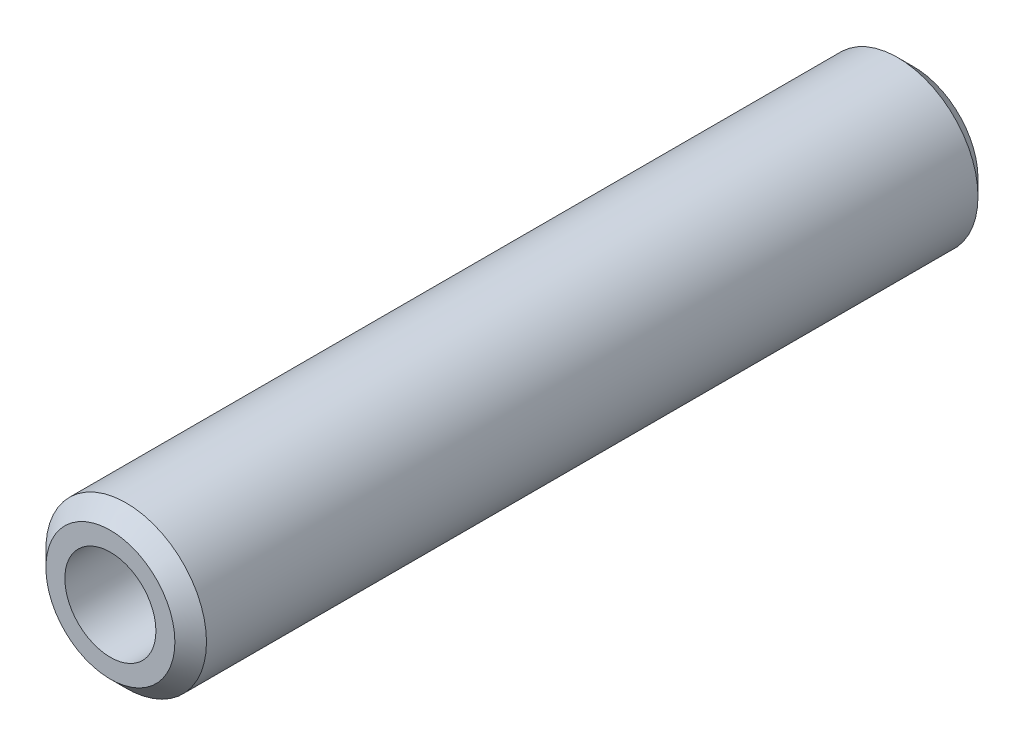
from build123d import *

# Parameters (mm, degrees)
SKETCH1_R           = 12.7
SKETCH1_R_2         = 7.2
BOSS_EXTRUDE1_DEPTH = 63.5
CHAMFER1_SIZE       = 2.5


with BuildPart() as part:
    # Sketch1 → Boss-Extrude1 (new body, symmetric)
    with BuildSketch(Plane.XY):
        Circle(SKETCH1_R)
        Circle(SKETCH1_R_2, mode=Mode.SUBTRACT)
    extrude(amount=BOSS_EXTRUDE1_DEPTH, both=True)

    # Chamfer1
    chamfer1_edges = [part.edges().sort_by_distance(p)[0] for p in [
        (-12.7, 0, -63.5),
        (-12.7, 0, 63.5),
    ]]
    chamfer(chamfer1_edges, length=CHAMFER1_SIZE)


solid = part.part
